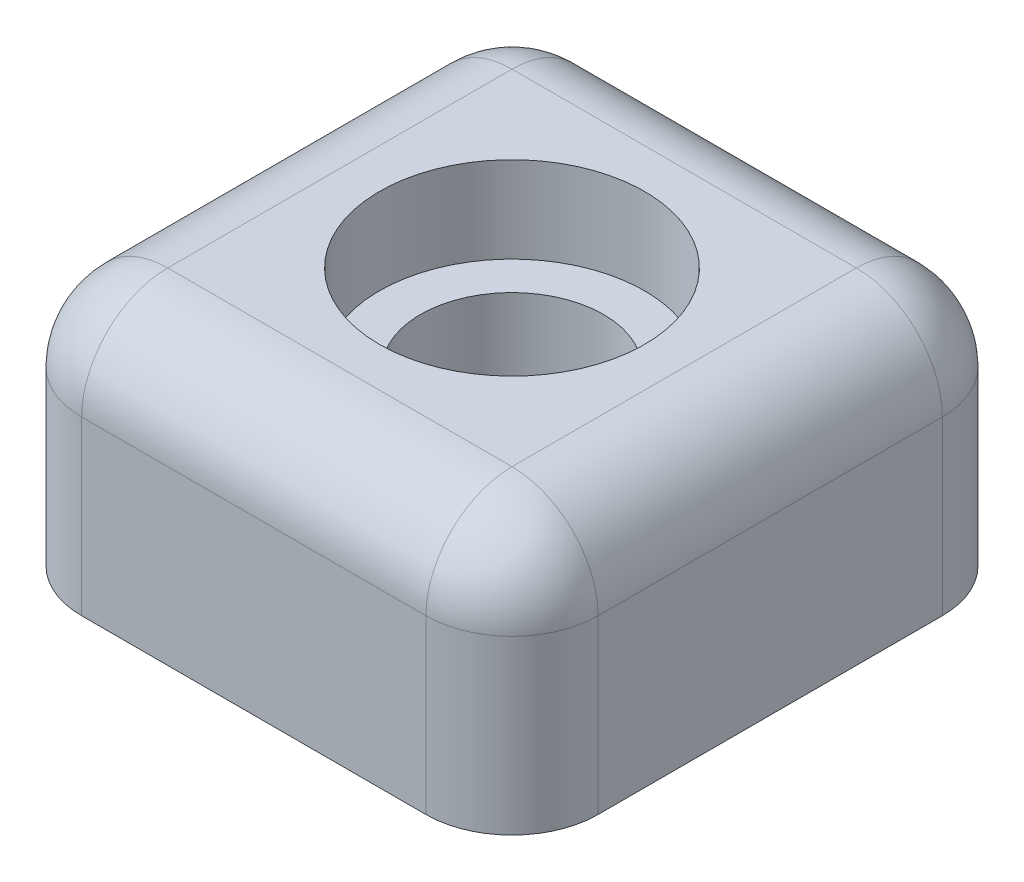
from build123d import *

# Parameters (mm, degrees)
SKETCH1_W           = 19.05
SKETCH1_H           = 19.05
SKETCH1_R           = 4.8895
BOSS_EXTRUDE1_DEPTH = 3.175
SKETCH3_W           = 19.05
SKETCH3_H           = 19.05
SKETCH3_R           = 3.3782
BOSS_EXTRUDE2_DEPTH = 3.175
SKETCH4_W           = 19.05
SKETCH4_H           = 19.05
BOSS_EXTRUDE3_DEPTH = 3.175
FILLET1_R           = 3.175


with BuildPart() as part:
    # Sketch1 → Boss-Extrude1 (new body)
    with BuildSketch(Plane(origin=(0, 0, 0), x_dir=(1, 0, 0), z_dir=(0, 1, 0))):
        Rectangle(SKETCH1_W, SKETCH1_H)
        Circle(SKETCH1_R, mode=Mode.SUBTRACT)
    extrude(amount=BOSS_EXTRUDE1_DEPTH)

    # Sketch3 → Boss-Extrude2 (add)
    with BuildSketch(Plane.XZ):
        Rectangle(SKETCH3_W, SKETCH3_H)
        Circle(SKETCH3_R, mode=Mode.SUBTRACT)
    extrude(amount=BOSS_EXTRUDE2_DEPTH)

    # Sketch4 → Boss-Extrude3 (add)
    with BuildSketch(Plane.XZ.offset(3.175)):
        Rectangle(SKETCH4_W, SKETCH4_H)
    extrude(amount=BOSS_EXTRUDE3_DEPTH)

    # Fillet1
    fillet1_edges = [part.edges().sort_by_distance(p)[0] for p in [
        (-9.525, 3.175, 0),
        (0, 3.175, 9.525),
        (9.525, 3.175, 0),
        (0, 3.175, -9.525),
        (9.525, -1.5875, 9.525),
        (-9.525, -1.5875, 9.525),
        (-9.525, -1.5875, -9.525),
        (9.525, -1.5875, -9.525),
    ]]
    fillet(fillet1_edges, radius=FILLET1_R)


solid = part.part
